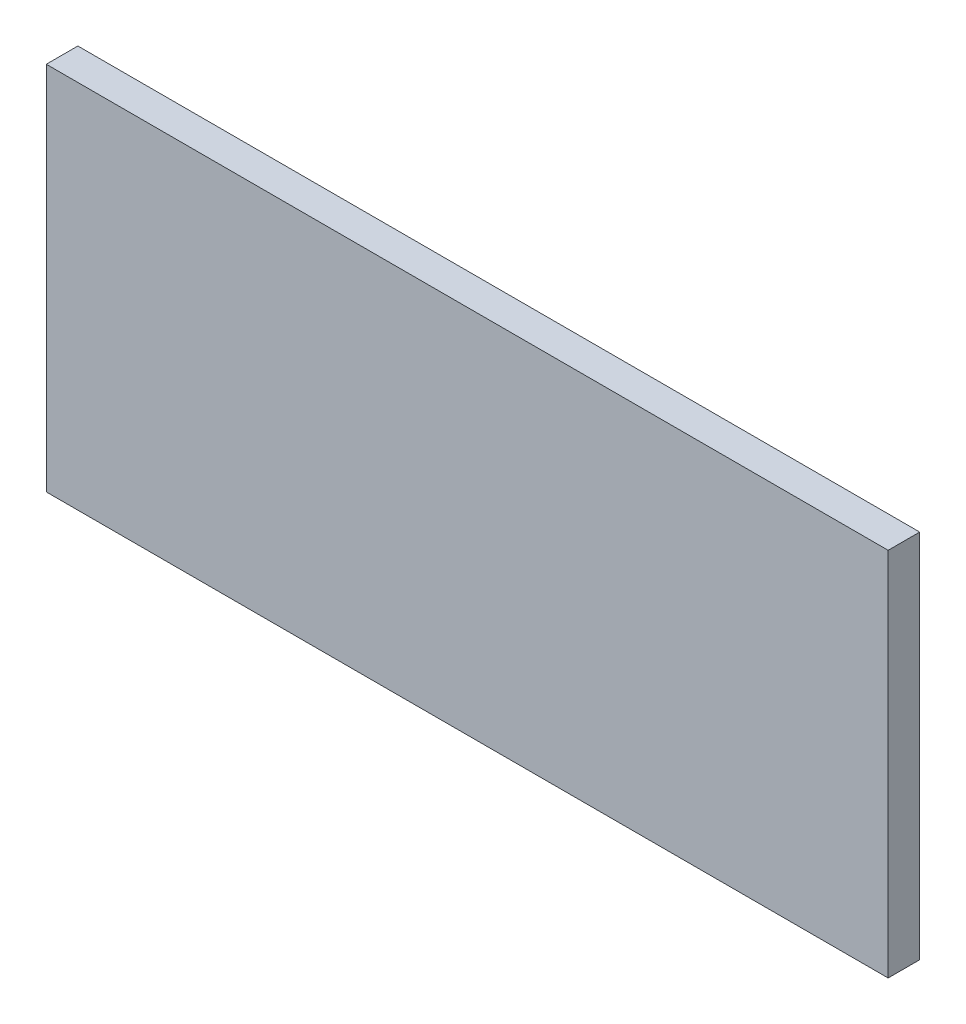
from build123d import *

# Parameters (mm, degrees)
BOSS_EXTRUDE1_DEPTH     = 15
SKETCH2_R               = 4
CUT_EXTRUDE1_DEPTH      = 10
LPATTERN1_COUNT         = 3
LPATTERN1_PITCH         = 142
SKETCH3_R               = 4
CUT_EXTRUDE2_DEPTH      = 10
LPATTERN2_COUNT         = 2
LPATTERN2_PITCH         = 106
MIRROR1_COPY_1_SKETCH_R = 4
MIRROR1_COPY_1_DEPTH    = 10
SKETCH4_W               = 400
SKETCH4_H               = 15
BOSS_EXTRUDE2_DEPTH     = 15


with BuildPart() as part:
    # Sketch1 → Boss-Extrude1 (new body)
    with BuildSketch(Plane.XY):
        Polygon((-200, -75.5), (-200, -85.5), (200, -85.5), (200, -75.5), (200, 75.5), (-200, 75.5), align=None)
    extrude(amount=BOSS_EXTRUDE1_DEPTH)

    # Sketch2 → Cut-Extrude1 (cut)
    with BuildSketch(Plane(origin=(0, 0, 0), x_dir=(-1, 0, 0), z_dir=(0, 0, -1))):
        with Locations((-142, -68)):
            Circle(SKETCH2_R)
    cut_extrude1 = extrude(amount=-CUT_EXTRUDE1_DEPTH, mode=Mode.SUBTRACT)

    # LPattern1: Cut-Extrude1 ×3
    with Locations(*[(-i * LPATTERN1_PITCH, 0, 0) for i in range(1, LPATTERN1_COUNT)]):
        add(cut_extrude1, mode=Mode.SUBTRACT)

    # Sketch3 → Cut-Extrude2 (cut)
    with BuildSketch(Plane(origin=(0, 0, 0), x_dir=(-1, 0, 0), z_dir=(0, 0, -1))):
        with Locations((-164.5, 60.5)):
            Circle(SKETCH3_R)
    cut_extrude2 = extrude(amount=-CUT_EXTRUDE2_DEPTH, mode=Mode.SUBTRACT)

    # LPattern2: Cut-Extrude2 ×2
    with Locations(*[(0, -i * LPATTERN2_PITCH, 0) for i in range(1, LPATTERN2_COUNT)]):
        add(cut_extrude2, mode=Mode.SUBTRACT)

    # Mirror1: Cut-Extrude2 across plane
    add(cut_extrude2.mirror(Plane(origin=(0, 0, 0), x_dir=(0, 0, 1), z_dir=(1, 0, 0))), mode=Mode.SUBTRACT)

    # Mirror1 copy 1 sketch → Mirror1 copy 1 (cut)
    with BuildSketch(Plane(origin=(0, -106, 0), x_dir=(1, 0, 0), z_dir=(0, 0, -1))):
        with Locations((-164.5, -60.5)):
            Circle(MIRROR1_COPY_1_SKETCH_R)
    extrude(amount=-MIRROR1_COPY_1_DEPTH, mode=Mode.SUBTRACT)

    # Sketch4 → Boss-Extrude2 (add)
    with BuildSketch(Plane.XY):
        with Locations((0, -93)):
            Rectangle(SKETCH4_W, SKETCH4_H)
    extrude(amount=BOSS_EXTRUDE2_DEPTH)


solid = part.part
